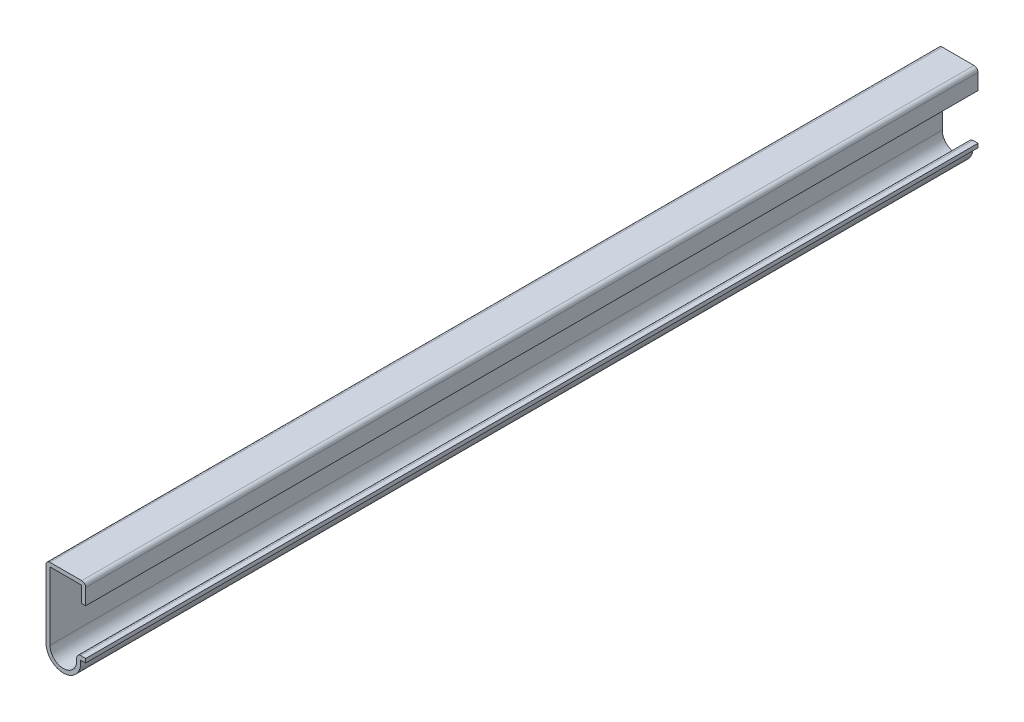
from build123d import *

# Parameters (mm, degrees)
EXTRUDE_THIN1_DEPTH = 285.75
FILLET1_R           = 1.27


with BuildPart() as part:
    # Sketch1 → Extrude-Thin1 (new body)
    with BuildSketch(Plane.XY):
        with BuildLine():
            Line((0, 0), (-1.5875, 0))
            Line((-1.5875, 0), (-1.5875, -0.79375))
            ThreePointArc((-1.5875, -0.79375), (-7.14375, -6.35), (-12.7, -0.79375))
            Line((-12.7, -0.79375), (-12.7, 22.225))
            Line((-12.7, 22.225), (0, 22.225))
            Line((0, 22.225), (0, 15.875))
            Line((0, 15.875), (-1.27, 15.875))
            Line((-1.27, 15.875), (-1.27, 20.955))
            Line((-1.27, 20.955), (-11.43, 20.955))
            Line((-11.43, 20.955), (-11.43, -0.79375))
            ThreePointArc((-11.43, -0.79375), (-7.14375, -5.08), (-2.8575, -0.79375))
            Line((-2.8575, -0.79375), (-2.8575, 1.27))
            Line((-2.8575, 1.27), (0, 1.27))
            Line((0, 1.27), (0, 0))
        make_face()
    extrude(amount=-EXTRUDE_THIN1_DEPTH)

    # Fillet1
    fillet1_edges = [part.edges().sort_by_distance(p)[0] for p in [
        (-2.8575, 1.27, -142.875),
        (-12.7, 22.225, -142.875),
        (0, 22.225, -142.875),
    ]]
    fillet(fillet1_edges, radius=FILLET1_R)


solid = part.part
